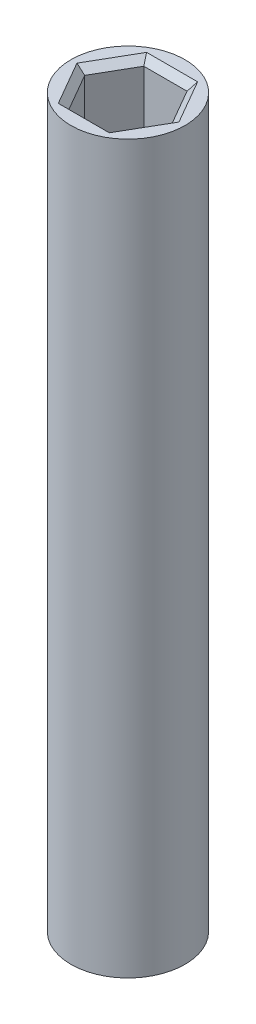
from build123d import *

# Parameters (mm, degrees)
SKETCH1_R           = 4.25
BOSS_EXTRUDE1_DEPTH = 54.11518367
CUT_EXTRUDE1_DEPTH  = 6.6
CHAMFER1_SIZE       = 0.5
CUT_EXTRUDE2_DEPTH  = 6.6
CHAMFER2_SIZE       = 0.5


with BuildPart() as part:
    # Sketch1 → Boss-Extrude1 (new body)
    with BuildSketch(Plane(origin=(0, 0, 0), x_dir=(1, 0, 0), z_dir=(0, 1, 0))):
        Circle(SKETCH1_R)
    extrude(amount=BOSS_EXTRUDE1_DEPTH)

    # Sketch2 → Cut-Extrude1 (cut)
    with BuildSketch(Plane(origin=(0, 54.11518367, 0), x_dir=(1, 0, 0), z_dir=(0, 1, 0))):
        Polygon((0, -2.79), (0, 2.79), (-1.610807251, 2.79), (-3.221614502, 0), (-1.610807251, -2.79), align=None)
        Polygon((1.610807251, 2.79), (0, 2.79), (0, -2.79), (1.610807251, -2.79), (3.221614502, 0), align=None)
    extrude(amount=-CUT_EXTRUDE1_DEPTH, mode=Mode.SUBTRACT)

    # Chamfer1
    chamfer1_edges = [part.edges().sort_by_distance(p)[0] for p in [
        (-2.416210877, 54.11518367, 1.395),
        (0, 54.11518367, 2.79),
        (2.416210877, 54.11518367, 1.395),
        (2.416210877, 54.11518367, -1.395),
        (0, 54.11518367, -2.79),
        (-2.416210877, 54.11518367, -1.395),
    ]]
    chamfer(chamfer1_edges, length=CHAMFER1_SIZE)

    # Sketch3 → Cut-Extrude2 (cut)
    with BuildSketch(Plane.XZ):
        Polygon((-1.361513121, 2.91977431), (1.361513121, -2.91977431), (-1.847842165, -2.638992105), (-3.209355286, 0.280782205), align=None)
        Polygon((1.847842165, 2.638992105), (-1.361513121, 2.91977431), (1.361513121, -2.91977431), (3.209355286, -0.280782205), align=None)
    extrude(amount=-CUT_EXTRUDE2_DEPTH, mode=Mode.SUBTRACT)

    # Chamfer2
    chamfer2_edges = [part.edges().sort_by_distance(p)[0] for p in [
        (-0.243164522, 0, -2.779383208),
        (2.285434204, 0, -1.600278257),
        (2.528598726, 0, 1.17910495),
        (0.243164522, 0, 2.779383208),
        (-2.285434204, 0, 1.600278257),
        (-2.528598726, 0, -1.17910495),
    ]]
    chamfer(chamfer2_edges, length=CHAMFER2_SIZE)


solid = part.part
